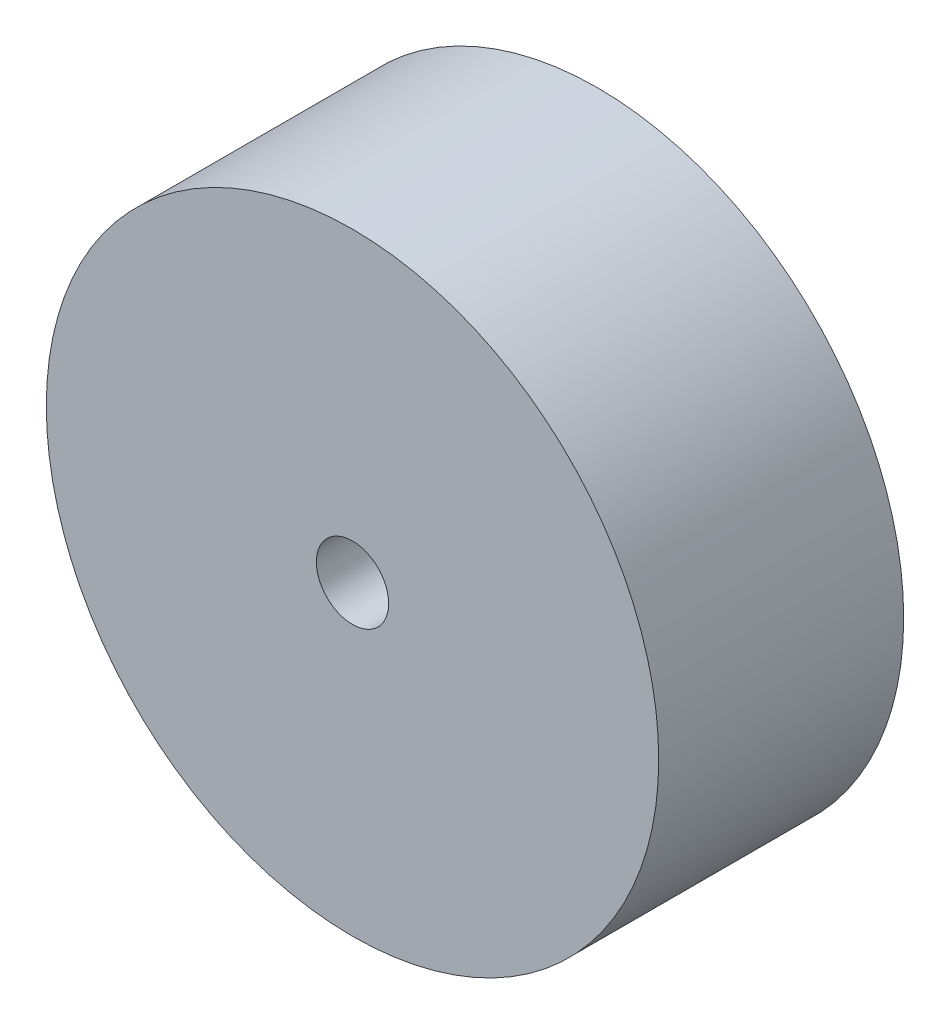
from build123d import *

# Parameters (mm, degrees)
SKETCH1_R           = 25.4
SKETCH1_R_2         = 3
BOSS_EXTRUDE1_DEPTH = 20.32


with BuildPart() as part:
    # Sketch1 → Boss-Extrude1 (new body)
    with BuildSketch(Plane.XY):
        Circle(SKETCH1_R)
        Circle(SKETCH1_R_2, mode=Mode.SUBTRACT)
    extrude(amount=BOSS_EXTRUDE1_DEPTH)


solid = part.part
